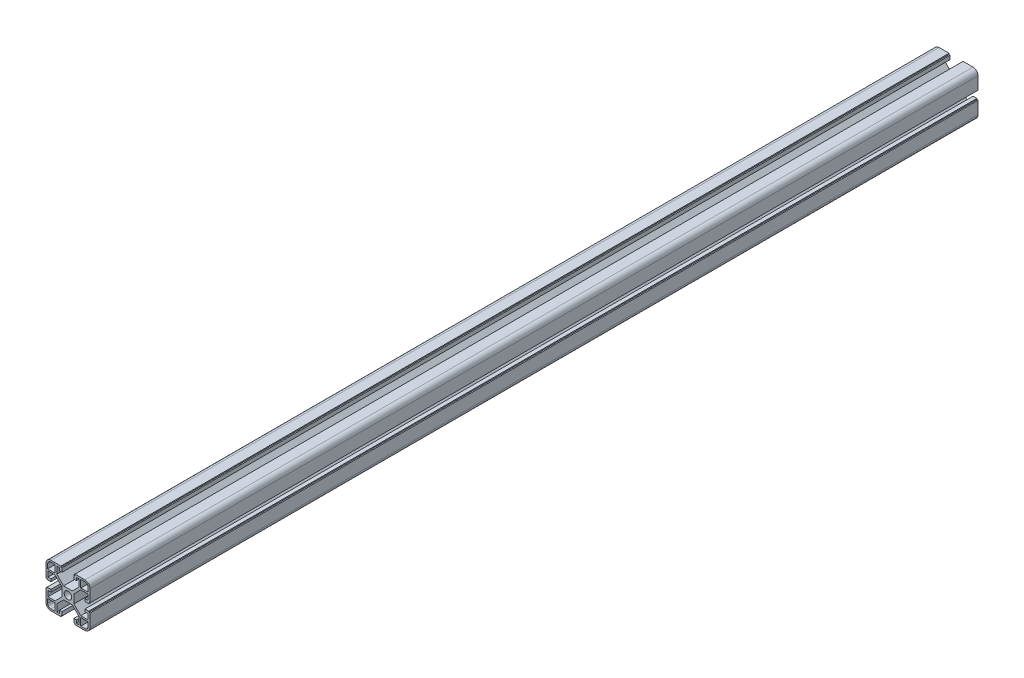
from build123d import *

# Parameters (mm, degrees)
BOSS_EXTRUDE1_DEPTH  = 810
MIRROR3_COPY_1_DEPTH = 810
MIRROR3_COPY_2_DEPTH = 810


with BuildPart() as part:
    # Sketch1 → Boss-Extrude1 (new body)
    with BuildSketch(Plane.XY):
        with BuildLine():
            Line((3.4, 0), (5.5, 0))
            Line((5.5, 0), (5.5, 4))
            Line((5.5, 4), (11.69, 10.19))
            Line((11.69, 10.19), (18.2, 10.19))
            Line((18.2, 10.19), (18.2, 5.265595036))
            Line((18.2, 5.265595036), (15.5, 5.265595036))
            Line((15.5, 5.265595036), (15.5, 2.965595036))
            Line((15.5, 2.965595036), (19, 2.965595036))
            Line((19, 2.965595036), (19, 3.965595036))
            Line((19, 3.965595036), (20, 3.965595036))
            Line((20, 3.965595036), (20, 15.5))
            ThreePointArc((20, 15.5), (18.681980515, 18.681980515), (15.5, 20))
            Line((15.5, 20), (6.385304712, 20))
            Line((6.385304712, 20), (6.385304712, 19))
            Line((6.385304712, 19), (5.385304712, 19))
            Line((5.385304712, 19), (5.385304712, 15.5))
            Line((5.385304712, 15.5), (7.685304712, 15.5))
            Line((7.685304712, 15.5), (7.685304712, 18.2))
            Line((7.685304712, 18.2), (10.19, 18.2))
            Line((10.19, 18.2), (10.19, 11.69))
            Line((10.19, 11.69), (4, 5.5))
            Line((4, 5.5), (0, 5.5))
            Line((0, 5.5), (0, 3.4))
            ThreePointArc((0, 3.4), (2.404163056, 2.404163056), (3.4, 0))
        make_face()
        with BuildLine():
            Line((18.5, 11.69), (18.5, 15.5))
            ThreePointArc((18.5, 15.5), (17.621320344, 17.621320344), (15.5, 18.5))
            Line((15.5, 18.5), (11.69, 18.5))
            Line((11.69, 18.5), (11.69, 11.69))
            Line((11.69, 11.69), (18.5, 11.69))
        make_face(mode=Mode.SUBTRACT)
    boss_extrude1 = extrude(amount=BOSS_EXTRUDE1_DEPTH)

    # Mirror1: Boss-Extrude1 across plane
    add(boss_extrude1.mirror(Plane.ZX))

    # Mirror2: Boss-Extrude1 across plane
    add(boss_extrude1.mirror(Plane(origin=(0, 0, 0), x_dir=(0, 0, 1), z_dir=(1, 0, 0))))

    # Mirror3 copy 1 sketch → Mirror3 copy 1 (add)
    with BuildSketch(Plane(origin=(0, 0, 0), x_dir=(-1, 0, 0), z_dir=(0, 0, 1))):
        with BuildLine():
            Line((3.4, 0), (5.5, 0))
            Line((5.5, 0), (5.5, 4))
            Line((5.5, 4), (11.69, 10.19))
            Line((11.69, 10.19), (18.2, 10.19))
            Line((18.2, 10.19), (18.2, 5.265595036))
            Line((18.2, 5.265595036), (15.5, 5.265595036))
            Line((15.5, 5.265595036), (15.5, 2.965595036))
            Line((15.5, 2.965595036), (19, 2.965595036))
            Line((19, 2.965595036), (19, 3.965595036))
            Line((19, 3.965595036), (20, 3.965595036))
            Line((20, 3.965595036), (20, 15.5))
            ThreePointArc((20, 15.5), (18.681980515, 18.681980515), (15.5, 20))
            Line((15.5, 20), (6.385304712, 20))
            Line((6.385304712, 20), (6.385304712, 19))
            Line((6.385304712, 19), (5.385304712, 19))
            Line((5.385304712, 19), (5.385304712, 15.5))
            Line((5.385304712, 15.5), (7.685304712, 15.5))
            Line((7.685304712, 15.5), (7.685304712, 18.2))
            Line((7.685304712, 18.2), (10.19, 18.2))
            Line((10.19, 18.2), (10.19, 11.69))
            Line((10.19, 11.69), (4, 5.5))
            Line((4, 5.5), (0, 5.5))
            Line((0, 5.5), (0, 3.4))
            ThreePointArc((0, 3.4), (2.404163056, 2.404163056), (3.4, 0))
        make_face()
        with BuildLine():
            Line((18.5, 11.69), (18.5, 15.5))
            ThreePointArc((18.5, 15.5), (17.621320344, 17.621320344), (15.5, 18.5))
            Line((15.5, 18.5), (11.69, 18.5))
            Line((11.69, 18.5), (11.69, 11.69))
            Line((11.69, 11.69), (18.5, 11.69))
        make_face(mode=Mode.SUBTRACT)
    extrude(amount=MIRROR3_COPY_1_DEPTH)

    # Mirror3 copy 2 sketch → Mirror3 copy 2 (add)
    with BuildSketch(Plane.XY):
        with BuildLine():
            Line((3.4, 0), (5.5, 0))
            Line((5.5, 0), (5.5, -4))
            Line((5.5, -4), (11.69, -10.19))
            Line((11.69, -10.19), (18.2, -10.19))
            Line((18.2, -10.19), (18.2, -5.265595036))
            Line((18.2, -5.265595036), (15.5, -5.265595036))
            Line((15.5, -5.265595036), (15.5, -2.965595036))
            Line((15.5, -2.965595036), (19, -2.965595036))
            Line((19, -2.965595036), (19, -3.965595036))
            Line((19, -3.965595036), (20, -3.965595036))
            Line((20, -3.965595036), (20, -15.5))
            ThreePointArc((20, -15.5), (18.681980515, -18.681980515), (15.5, -20))
            Line((15.5, -20), (6.385304712, -20))
            Line((6.385304712, -20), (6.385304712, -19))
            Line((6.385304712, -19), (5.385304712, -19))
            Line((5.385304712, -19), (5.385304712, -15.5))
            Line((5.385304712, -15.5), (7.685304712, -15.5))
            Line((7.685304712, -15.5), (7.685304712, -18.2))
            Line((7.685304712, -18.2), (10.19, -18.2))
            Line((10.19, -18.2), (10.19, -11.69))
            Line((10.19, -11.69), (4, -5.5))
            Line((4, -5.5), (0, -5.5))
            Line((0, -5.5), (0, -3.4))
            ThreePointArc((0, -3.4), (2.404163056, -2.404163056), (3.4, 0))
        make_face()
        with BuildLine():
            Line((18.5, -11.69), (18.5, -15.5))
            ThreePointArc((18.5, -15.5), (17.621320344, -17.621320344), (15.5, -18.5))
            Line((15.5, -18.5), (11.69, -18.5))
            Line((11.69, -18.5), (11.69, -11.69))
            Line((11.69, -11.69), (18.5, -11.69))
        make_face(mode=Mode.SUBTRACT)
    extrude(amount=MIRROR3_COPY_2_DEPTH)


solid = part.part
